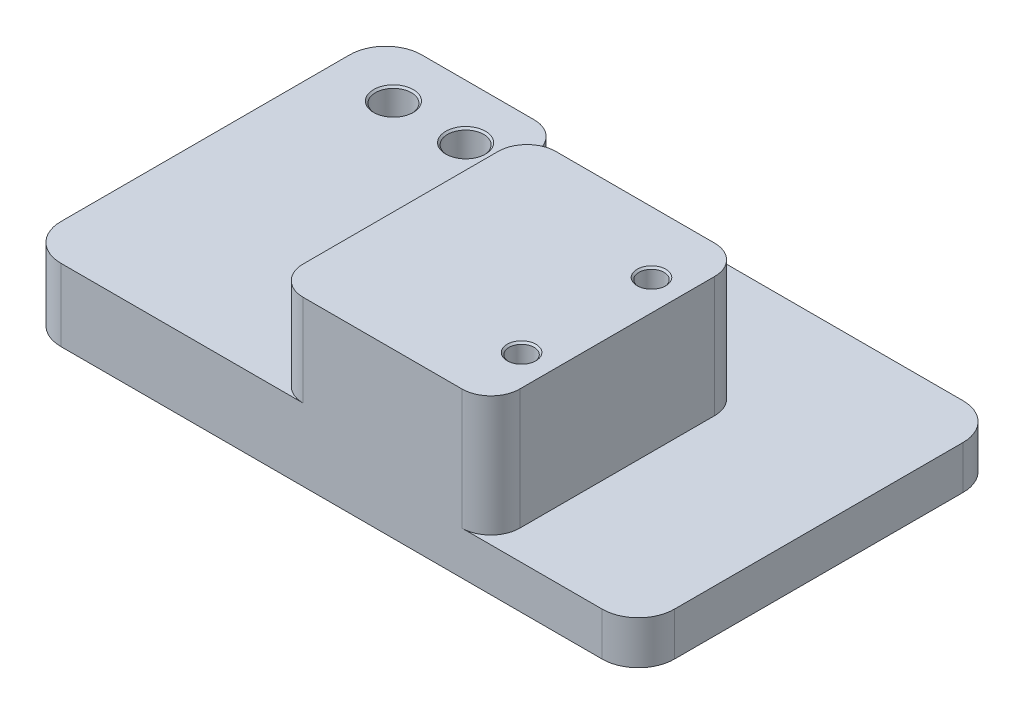
from build123d import *

# Parameters (mm, degrees)
SKETCH1_W           = 85
SKETCH1_H           = 50
BOSS_EXTRUDE1_DEPTH = 6
BOSS_EXTRUDE2_DEPTH = 4
SKETCH4_R           = 2.5
CUT_EXTRUDE2_DEPTH  = 11
SKETCH5_W           = 55
SKETCH5_H           = 35
BOSS_EXTRUDE3_DEPTH = 16.7
FILLET1_R           = 5
SKETCH6_R           = 1.74
CUT_EXTRUDE3_DEPTH  = 10
SKETCH7_W           = 25
SKETCH7_H           = 35
CUT_EXTRUDE4_DEPTH  = 12.7
FILLET3_R           = 4
FILLET4_R           = 4
FILLET5_R           = 4
CHAMFER1_SIZE       = 0.25


with BuildPart() as part:
    # Sketch1 → Boss-Extrude1 (new body)
    with BuildSketch(Plane(origin=(0, 0, 0), x_dir=(1, 0, 0), z_dir=(0, 1, 0))):
        with Locations((42.5, 25)):
            Rectangle(SKETCH1_W, SKETCH1_H)
    extrude(amount=BOSS_EXTRUDE1_DEPTH)

    # Sketch2 → Boss-Extrude2 (add)
    with BuildSketch(Plane(origin=(0, 6, 0), x_dir=(1, 0, 0), z_dir=(0, 1, 0))):
        Polygon((0, 0), (0, 50), (24.574331447, 50), (24.574331447, 35), (9.574331447, 35), (9.574331447, 0), align=None)
    extrude(amount=BOSS_EXTRUDE2_DEPTH)

    # Sketch4 → Cut-Extrude2 (cut)
    with BuildSketch(Plane(origin=(0, 10, 0), x_dir=(1, 0, 0), z_dir=(0, 1, 0))):
        with Locations((18.574331447, 42.5)):
            Circle(SKETCH4_R)
        with Locations((8.574331447, 42.5)):
            Circle(SKETCH4_R)
    extrude(amount=-CUT_EXTRUDE2_DEPTH, mode=Mode.SUBTRACT)

    # Sketch5 → Boss-Extrude3 (add)
    with BuildSketch(Plane(origin=(0, 6, 0), x_dir=(1, 0, 0), z_dir=(0, 1, 0))):
        with Locations((37.074331447, 17.5)):
            Rectangle(SKETCH5_W, SKETCH5_H)
    extrude(amount=BOSS_EXTRUDE3_DEPTH)

    # Fillet1
    fillet1_edges = [part.edges().sort_by_distance(p)[0] for p in [
        (0, 5, -50),
        (85, 3, -50),
        (85, 3, 0),
        (0, 5, 0),
    ]]
    fillet(fillet1_edges, radius=FILLET1_R)

    # Sketch6 → Cut-Extrude3 (cut)
    with BuildSketch(Plane(origin=(0, 22.7, 0), x_dir=(1, 0, 0), z_dir=(0, 1, 0))):
        with Locations((60.324331447, 26.5)):
            Circle(SKETCH6_R)
        with Locations((60.324331447, 8.5)):
            Circle(SKETCH6_R)
    extrude(amount=-CUT_EXTRUDE3_DEPTH, mode=Mode.SUBTRACT)

    # Sketch7 → Cut-Extrude4 (cut)
    with BuildSketch(Plane(origin=(0, 22.7, 0), x_dir=(1, 0, 0), z_dir=(0, 1, 0))):
        with Locations((22.074331447, 17.5)):
            Rectangle(SKETCH7_W, SKETCH7_H)
    extrude(amount=-CUT_EXTRUDE4_DEPTH, mode=Mode.SUBTRACT)

    # Fillet3
    fillet3_edges = [part.edges().sort_by_distance(p)[0] for p in [
        (34.574331447, 16.35, 0),
        (34.574331447, 16.35, -35),
        (64.574331447, 14.35, -35),
        (64.574331447, 14.35, 0),
    ]]
    fillet(fillet3_edges, radius=FILLET3_R)

    # Fillet4
    fillet4_edges = [part.edges().sort_by_distance(p)[0] for p in [
        (24.574331447, 8, -35),
    ]]
    fillet(fillet4_edges, radius=FILLET4_R)

    # Fillet5
    fillet5_edges = [part.edges().sort_by_distance(p)[0] for p in [
        (24.574331447, 8, -50),
    ]]
    fillet(fillet5_edges, radius=FILLET5_R)

    # Chamfer1
    chamfer1_edges = [part.edges().sort_by_distance(p)[0] for p in [
        (16.074331447, 10, -42.5),
        (6.074331447, 10, -42.5),
        (58.584331447, 22.7, -26.5),
        (58.584331447, 22.7, -8.5),
    ]]
    chamfer(chamfer1_edges, length=CHAMFER1_SIZE)


solid = part.part
